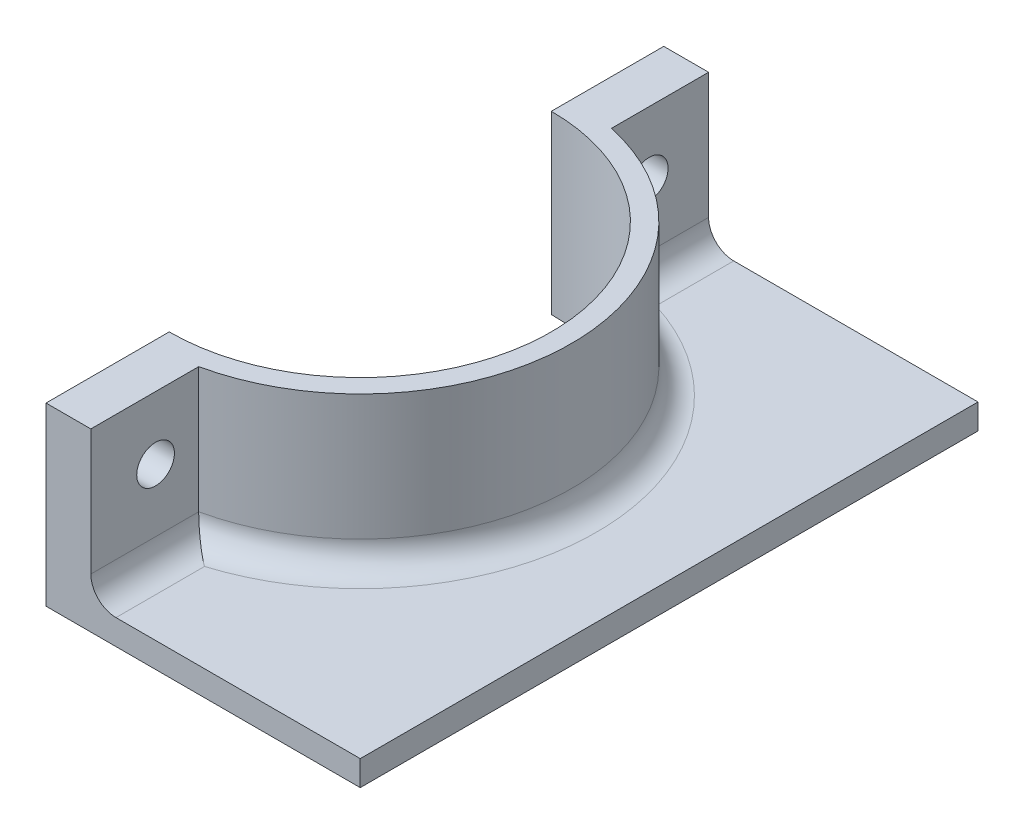
from build123d import *

# Parameters (mm, degrees)
BOSS_EXTRUDE12_DEPTH    = 17.78
BOSS_EXTRUDE13_DEPTH    = 2.54
FILLET2_R               = 2.54
CUT_EXTRUDE1_DEPTH      = 87.475655963
CUT_EXTRUDE1_DEPTH_BACK = 87.475655963
SKETCH5_R               = 1.905


with BuildPart() as part:
    # Sketch3 → Boss-Extrude12 (new body)
    with BuildSketch(Plane(origin=(0, 0, 0), x_dir=(1, 0, 0), z_dir=(0, 1, 0))):
        with BuildLine():
            Line((25.4, 12.446), (25.4, 0))
            Line((25.4, 0), (29.929832056, 0))
            Line((29.929832056, 0), (29.929832056, 10.900407257))
            ThreePointArc((29.929832056, 10.900407257), (46.736, 31.75), (29.929832056, 52.599592743))
            Line((29.929832056, 52.599592743), (29.929832056, 62.41624918))
            Line((29.929832056, 62.41624918), (25.4, 62.41624918))
            Line((25.4, 62.41624918), (25.4, 51.054))
            ThreePointArc((25.4, 51.054), (39.049989304, 45.399989304), (44.704, 31.75))
            ThreePointArc((44.704, 31.75), (39.049989304, 18.100010696), (25.4, 12.446))
        make_face()
    extrude(amount=BOSS_EXTRUDE12_DEPTH)

    # Sketch3_16 → Boss-Extrude13 (add)
    with BuildSketch(Plane(origin=(0, 0, 0), x_dir=(1, 0, 0), z_dir=(0, 1, 0))):
        with BuildLine():
            Line((29.929832056, 10.900407257), (29.929832056, 0))
            Line((29.929832056, 0), (57.15, 0))
            Line((57.15, 0), (57.15, 62.41624918))
            Line((57.15, 62.41624918), (29.929832056, 62.41624918))
            Line((29.929832056, 62.41624918), (29.929832056, 52.599592743))
            ThreePointArc((29.929832056, 52.599592743), (46.736, 31.75), (29.929832056, 10.900407257))
        make_face()
    extrude(amount=BOSS_EXTRUDE13_DEPTH)

    # Fillet2
    fillet2_edges = [part.edges().sort_by_distance(p)[0] for p in [
        (29.929832056, 2.54, -57.507920962),
        (46.736, 2.54, -31.75),
        (29.929832056, 2.54, -5.450203629),
    ]]
    fillet(fillet2_edges, radius=FILLET2_R)

    # Sketch5 → Cut-Extrude1 (cut, two sides: drawn at the far end of the back side and taken through both)
    with BuildSketch(Plane(origin=(0, 0, 0), x_dir=(0, 0, -1), z_dir=(1, 0, 0)).offset(-CUT_EXTRUDE1_DEPTH_BACK)):
        with Locations((6.5405, 11.43)):
            Circle(SKETCH5_R)
        with Locations((56.41762459, 11.43)):
            Circle(SKETCH5_R)
    extrude(amount=CUT_EXTRUDE1_DEPTH + CUT_EXTRUDE1_DEPTH_BACK, mode=Mode.SUBTRACT)


solid = part.part
